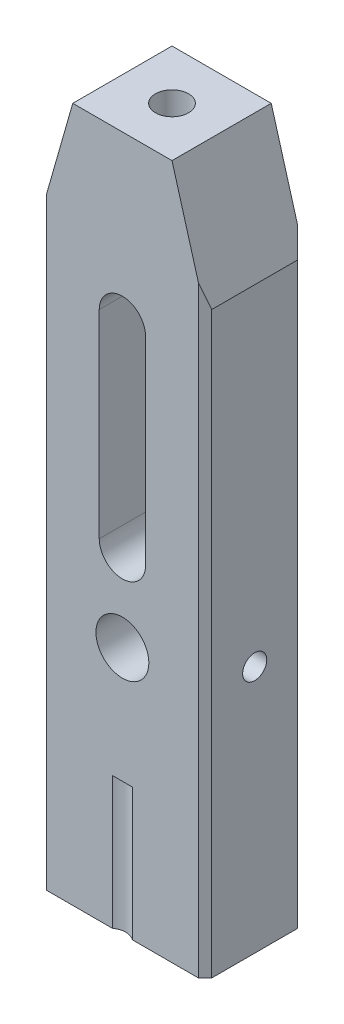
from build123d import *

# Parameters (mm, degrees)
SKETCH2_W           = 50
SKETCH2_H           = 30
BOSS_EXTRUDE2_DEPTH = 210
CUT_EXTRUDE2_REACH  = 32
SKETCH3_R           = 8
CUT_EXTRUDE5_REACH  = 32
CUT_EXTRUDE8_REACH  = 32
CHAMFER3_SIZE       = 2
CUT_EXTRUDE10_DEPTH = 40
SKETCH16_R          = 3.65
CUT_EXTRUDE11_DEPTH = 50
SKETCH20_R          = 5
CUT_EXTRUDE13_DEPTH = 35


with BuildPart() as part:
    # Sketch2 → Boss-Extrude2 (new body)
    with BuildSketch(Plane(origin=(0, 0, 0), x_dir=(1, 0, 0), z_dir=(0, 1, 0))):
        with Locations((25, 15)):
            Rectangle(SKETCH2_W, SKETCH2_H)
    extrude(amount=BOSS_EXTRUDE2_DEPTH)

    # Sketch3 → Cut-Extrude2 (cut, up to next)
    with BuildSketch(Plane.XY, mode=Mode.PRIVATE) as cut_extrude2_sk1:
        with Locations((25, 75)):
            Circle(SKETCH3_R)
    cut_extrude2_tool1 = extrude(cut_extrude2_sk1.sketch, amount=-CUT_EXTRUDE2_REACH, mode=Mode.PRIVATE) & part.part
    add(cut_extrude2_tool1.solids().sort_by_distance((25, 75, 0))[0], mode=Mode.SUBTRACT)

    # Sketch7 → Cut-Extrude5 (cut, up to next)
    with BuildSketch(Plane.XY, mode=Mode.PRIVATE) as cut_extrude5_sk1:
        Polygon((0, 175), (10, 210), (0, 210), align=None)
    cut_extrude5_tool1 = extrude(cut_extrude5_sk1.sketch, amount=-CUT_EXTRUDE5_REACH, mode=Mode.PRIVATE) & part.part
    add(cut_extrude5_tool1.solids().sort_by_distance((3.333333, 198.333333, 0))[0], mode=Mode.SUBTRACT)
    # Sketch7 → Cut-Extrude5 (cut, up to next)
    with BuildSketch(Plane.XY, mode=Mode.PRIVATE) as cut_extrude5_sk2:
        Polygon((50, 210), (50, 175), (40, 210), align=None)
    cut_extrude5_tool2 = extrude(cut_extrude5_sk2.sketch, amount=-CUT_EXTRUDE5_REACH, mode=Mode.PRIVATE) & part.part
    add(cut_extrude5_tool2.solids().sort_by_distance((46.666667, 198.333333, 0))[0], mode=Mode.SUBTRACT)

    # Sketch11 → Cut-Extrude8 (cut, up to next)
    with BuildSketch(Plane(origin=(0, 0, -30), x_dir=(-1, 0, 0), z_dir=(0, 0, -1)), mode=Mode.PRIVATE) as cut_extrude8_sk1:
        with BuildLine():
            Line((-18, 160), (-18, 100))
            ThreePointArc((-18, 100), (-25, 93), (-32, 100))
            Line((-32, 100), (-32, 160))
            ThreePointArc((-32, 160), (-25, 167), (-18, 160))
        make_face()
    cut_extrude8_tool1 = extrude(cut_extrude8_sk1.sketch, amount=-CUT_EXTRUDE8_REACH, mode=Mode.PRIVATE) & part.part
    add(cut_extrude8_tool1.solids().sort_by_distance((25, 130, -30))[0], mode=Mode.SUBTRACT)

    # Chamfer3
    chamfer3_edges = [part.edges().sort_by_distance(p)[0] for p in [
        (0, 87.5, -30),
        (50, 87.5, -30),
        (50, 87.5, 0),
        (0, 87.5, 0),
    ]]
    chamfer(chamfer3_edges, length=CHAMFER3_SIZE)

    # Sketch15 → Cut-Extrude10 (cut)
    with BuildSketch(Plane.XZ):
        with BuildLine():
            Line((22, 0), (28, 0))
            ThreePointArc((28, 0), (25, -1), (22, 0))
        make_face()
        with BuildLine():
            Line((22, -30), (28, -30))
            ThreePointArc((28, -30), (25, -29), (22, -30))
        make_face()
    extrude(amount=-CUT_EXTRUDE10_DEPTH, mode=Mode.SUBTRACT)

    # Sketch16 → Cut-Extrude11 (cut)
    with BuildSketch(Plane(origin=(50, 0, 0), x_dir=(0, 0, -1), z_dir=(1, 0, 0))):
        with Locations((15, 75)):
            Circle(SKETCH16_R)
    extrude(amount=-CUT_EXTRUDE11_DEPTH, mode=Mode.SUBTRACT)

    # Sketch20 → Cut-Extrude13 (cut)
    with BuildSketch(Plane(origin=(0, 210, 0), x_dir=(1, 0, 0), z_dir=(0, 1, 0))):
        with Locations((25, 15)):
            Circle(SKETCH20_R)
    extrude(amount=-CUT_EXTRUDE13_DEPTH, mode=Mode.SUBTRACT)


solid = part.part
